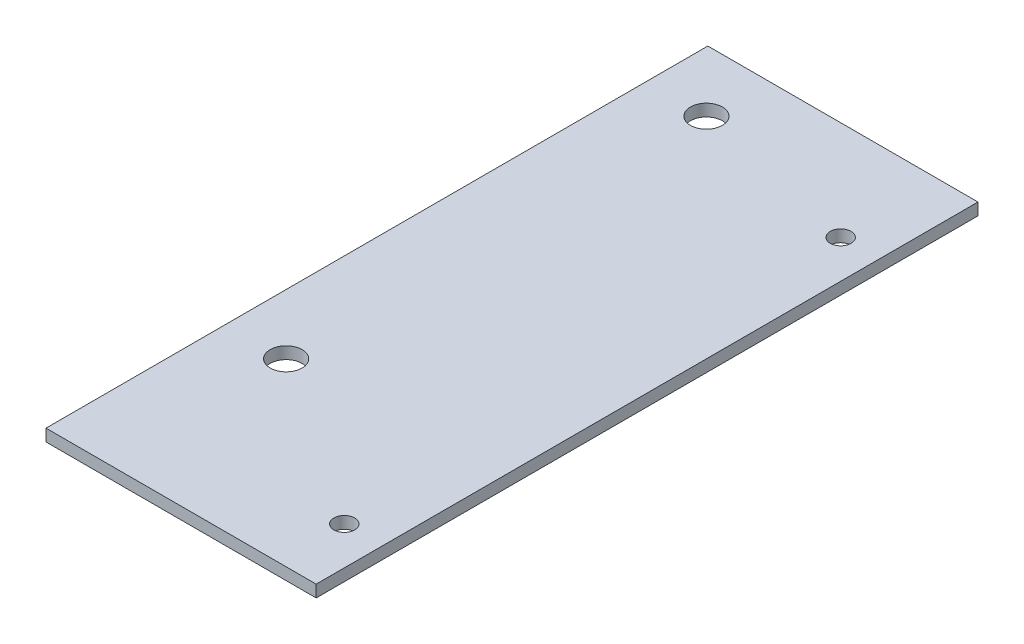
from build123d import *

# Parameters (mm, degrees)
SKETCH1_W               = 57.15
SKETCH1_H               = 140
BOSS_EXTRUDE1_DEPTH     = 2.54
SKETCH2_R               = 2.2
CUT_EXTRUDE1_DEPTH      = 3.54
SKETCH3_R               = 3.3782
CUT_EXTRUDE2_DEPTH      = 1
CUT_EXTRUDE2_DEPTH_BACK = 3.54


with BuildPart() as part:
    # Sketch1 → Boss-Extrude1 (new body)
    with BuildSketch(Plane(origin=(0, 0, 0), x_dir=(1, 0, 0), z_dir=(0, 1, 0))):
        with Locations((28.575, 70)):
            Rectangle(SKETCH1_W, SKETCH1_H)
    extrude(amount=BOSS_EXTRUDE1_DEPTH)

    # Sketch2 → Cut-Extrude1 (cut, through all)
    with BuildSketch(Plane.XZ):
        with Locations((49.1, -119)):
            Circle(SKETCH2_R)
        with Locations((49.1, -14)):
            Circle(SKETCH2_R)
    extrude(amount=-CUT_EXTRUDE1_DEPTH, mode=Mode.SUBTRACT)

    # Sketch3 → Cut-Extrude2 (cut, two sides)
    with BuildSketch(Plane.XZ) as cut_extrude2_sk:
        with Locations((12.7, -127)):
            Circle(SKETCH3_R)
        with Locations((12.7, -38.1)):
            Circle(SKETCH3_R)
    extrude(amount=CUT_EXTRUDE2_DEPTH, mode=Mode.SUBTRACT)
    extrude(cut_extrude2_sk.sketch, amount=-CUT_EXTRUDE2_DEPTH_BACK, mode=Mode.SUBTRACT)


solid = part.part
